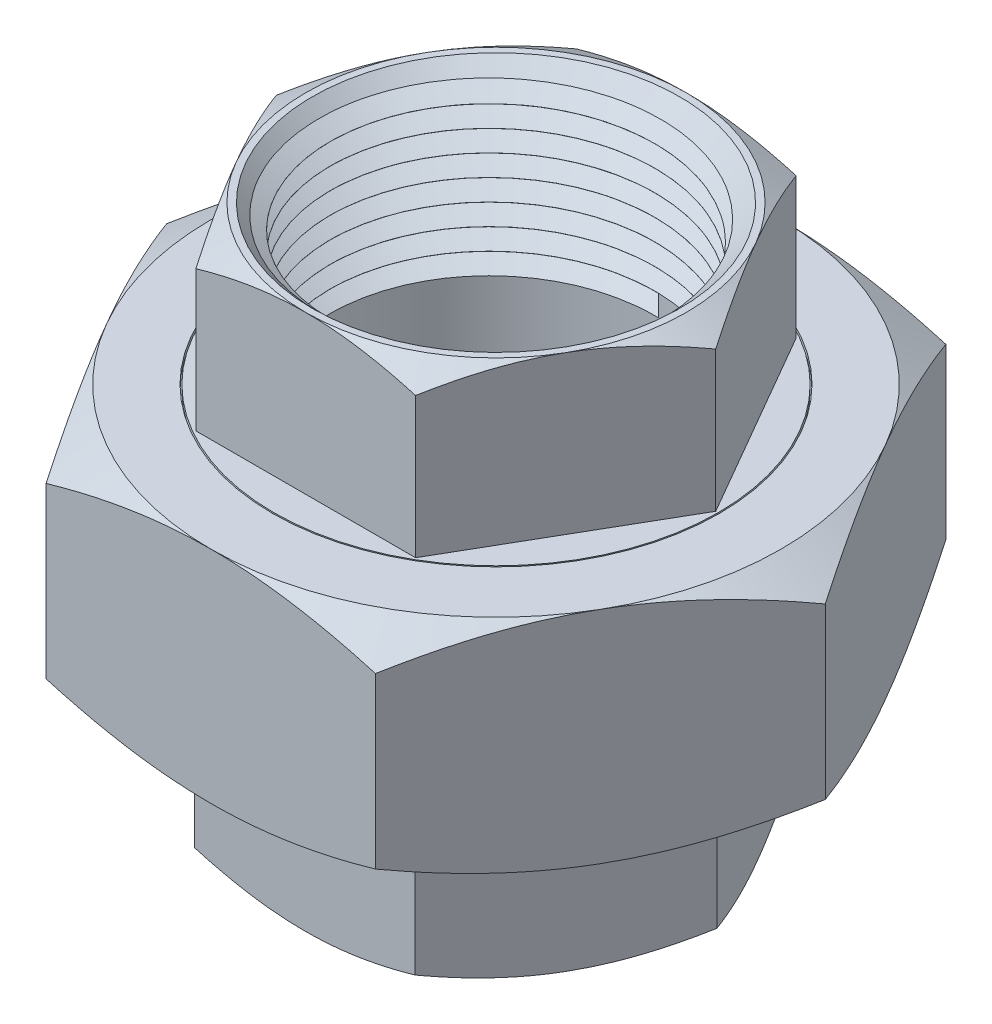
from build123d import *

# Parameters (mm, degrees)
BOSS_EXTRUDE1_DEPTH    = 20.7
SKETCH2_R              = 21
SKETCH2_R_2            = 20.875
CUT_EXTRUDE1_DEPTH     = 0.5
BOSS_EXTRUDE7_DEPTH    = 14.8
BOSS_EXTRUDE8_DEPTH    = 14.8
SKETCH7_OUTSIDE_W      = 100.43
SKETCH7_OUTSIDE_H      = 92.138
SKETCH7_OUTSIDE_R      = 26.8
CUT_EXTRUDE3_DEPTH     = 5
CUT_EXTRUDE3_TAPER     = 60
SKETCH8_OUTSIDE_W      = 100.43
SKETCH8_OUTSIDE_H      = 92.138
SKETCH8_OUTSIDE_R      = 26.8
CUT_EXTRUDE4_DEPTH     = 5
CUT_EXTRUDE4_TAPER     = 60
SKETCH9_OUTSIDE_W      = 100.43
SKETCH9_OUTSIDE_H      = 92.138
SKETCH9_OUTSIDE_R      = 17.970027129
CUT_EXTRUDE5_DEPTH     = 5
CUT_EXTRUDE5_TAPER     = 60
SKETCH10_OUTSIDE_W     = 100.43
SKETCH10_OUTSIDE_H     = 92.138
SKETCH10_OUTSIDE_R     = 17.883424588
CUT_EXTRUDE6_DEPTH     = 5
CUT_EXTRUDE6_TAPER     = 60
SKETCH14_R             = 15.25
CUT_EXTRUDE7_DEPTH     = 51.3
CHAMFER1_SIZE          = 2
CUT_SWEEP2_PITCH       = 2
CUT_SWEEP2_HEIGHT      = 15
CUT_SWEEP2_RADIUS      = 15.25
CUT_SWEEP2_START_ANGLE = 180
CUT_SWEEP3_PITCH       = 2
CUT_SWEEP3_HEIGHT      = 15
CUT_SWEEP3_RADIUS      = 15.25
CUT_SWEEP3_START_ANGLE = 180


with BuildPart() as part:
    # Sketch1 → Boss-Extrude1 (new body)
    with BuildSketch(Plane(origin=(0, 0, 0), x_dir=(1, 0, 0), z_dir=(0, 1, 0))):
        Polygon((30.945974429, 0), (15.472987214, 26.8), (-15.472987214, 26.8), (-30.945974429, 0), (-15.472987214, -26.8), (15.472987214, -26.8), align=None)
    extrude(amount=BOSS_EXTRUDE1_DEPTH)

    # Sketch2 → Cut-Extrude1 (cut)
    with BuildSketch(Plane(origin=(0, 20.7, 0), x_dir=(1, 0, 0), z_dir=(0, 1, 0))):
        Circle(SKETCH2_R)
        Circle(SKETCH2_R_2, mode=Mode.SUBTRACT)
    extrude(amount=-CUT_EXTRUDE1_DEPTH, mode=Mode.SUBTRACT)

    # Sketch5 → Boss-Extrude7 (add)
    with BuildSketch(Plane(origin=(0, 20.7, 0), x_dir=(1, 0, 0), z_dir=(0, 1, 0))):
        Polygon((20.65, 0), (10.325, 17.883424588), (-10.325, 17.883424588), (-20.65, 0), (-10.325, -17.883424588), (10.325, -17.883424588), align=None)
    extrude(amount=BOSS_EXTRUDE7_DEPTH)

    # Sketch6 → Boss-Extrude8 (add)
    with BuildSketch(Plane.XZ):
        Polygon((20.75, 0), (10.375, 17.970027129), (-10.375, 17.970027129), (-20.75, 0), (-10.375, -17.970027129), (10.375, -17.970027129), align=None)
    extrude(amount=BOSS_EXTRUDE8_DEPTH)

    # Sketch7 outside → Cut-Extrude3 (cut)
    with BuildSketch(Plane.XZ):
        Rectangle(SKETCH7_OUTSIDE_W, SKETCH7_OUTSIDE_H)
        Circle(SKETCH7_OUTSIDE_R, mode=Mode.SUBTRACT)
    extrude(amount=-CUT_EXTRUDE3_DEPTH, taper=CUT_EXTRUDE3_TAPER, mode=Mode.SUBTRACT)

    # Sketch8 outside → Cut-Extrude4 (cut)
    with BuildSketch(Plane(origin=(0, 20.7, 0), x_dir=(1, 0, 0), z_dir=(0, 1, 0))):
        Rectangle(SKETCH8_OUTSIDE_W, SKETCH8_OUTSIDE_H)
        Circle(SKETCH8_OUTSIDE_R, mode=Mode.SUBTRACT)
    extrude(amount=-CUT_EXTRUDE4_DEPTH, taper=CUT_EXTRUDE4_TAPER, mode=Mode.SUBTRACT)

    # Sketch9 outside → Cut-Extrude5 (cut)
    with BuildSketch(Plane.XZ.offset(14.8)):
        Rectangle(SKETCH9_OUTSIDE_W, SKETCH9_OUTSIDE_H)
        Circle(SKETCH9_OUTSIDE_R, mode=Mode.SUBTRACT)
    extrude(amount=-CUT_EXTRUDE5_DEPTH, taper=CUT_EXTRUDE5_TAPER, mode=Mode.SUBTRACT)

    # Sketch10 outside → Cut-Extrude6 (cut)
    with BuildSketch(Plane(origin=(0, 35.5, 0), x_dir=(1, 0, 0), z_dir=(0, 1, 0))):
        Rectangle(SKETCH10_OUTSIDE_W, SKETCH10_OUTSIDE_H)
        Circle(SKETCH10_OUTSIDE_R, mode=Mode.SUBTRACT)
    extrude(amount=-CUT_EXTRUDE6_DEPTH, taper=CUT_EXTRUDE6_TAPER, mode=Mode.SUBTRACT)

    # Cut-Sweep1: sweep along a path in Sketch13
    with BuildLine(Plane.XZ) as cut_sweep1_path:
        CenterArc((0, 0), 23.25, 0, 360)
    # Sketch12 → Cut-Sweep1 (sweep, cut)
    with BuildSketch(Plane(origin=(0, 0, 0), x_dir=(0, 0, -1), z_dir=(1, 0, 0))):
        Polygon((23.25, 1.335741012), (22.434038991, 0), (24.10439639, 0), align=None)
    sweep(path=cut_sweep1_path.line, mode=Mode.SUBTRACT)

    # Sketch14 → Cut-Extrude7 (cut, through all)
    with BuildSketch(Plane.XZ.offset(14.8)):
        Circle(SKETCH14_R)
    extrude(amount=-CUT_EXTRUDE7_DEPTH, mode=Mode.SUBTRACT)

    # Chamfer1
    chamfer1_edges = [part.edges().sort_by_distance(p)[0] for p in [
        (-15.25, 35.5, 0),
        (-15.25, -14.8, 0),
    ]]
    chamfer(chamfer1_edges, length=CHAMFER1_SIZE)

    # Cut-Sweep2: sweep along a helix
    with BuildLine() as cut_sweep2_path:
        add(Helix(CUT_SWEEP2_PITCH, CUT_SWEEP2_HEIGHT, CUT_SWEEP2_RADIUS, center=(0, -14.8, 0), direction=(0, 1, 0), mode=Mode.PRIVATE).rotate(Axis((0, -14.8, 0), (0, 1, 0)), CUT_SWEEP2_START_ANGLE))
    # Sketch16 → Cut-Sweep2 (sweep, cut)
    with BuildSketch(Plane(origin=(0, 0, 0), x_dir=(0, 0, -1), z_dir=(1, 0, 0))):
        Polygon((15.205623927, -14.8), (15.205623927, -12.81), (16.94055188, -13.805), align=None)
    sweep(path=cut_sweep2_path.line, is_frenet=True, mode=Mode.SUBTRACT)

    # Cut-Sweep3: sweep along a helix
    with BuildLine() as cut_sweep3_path:
        add(Helix(CUT_SWEEP3_PITCH, CUT_SWEEP3_HEIGHT, CUT_SWEEP3_RADIUS, center=(0, 35.5, 0), direction=(0, -1, 0), mode=Mode.PRIVATE).rotate(Axis((0, 35.5, 0), (0, -1, 0)), CUT_SWEEP3_START_ANGLE))
    # Sketch18 → Cut-Sweep3 (sweep, cut)
    with BuildSketch(Plane(origin=(0, 0, 0), x_dir=(0, 0, -1), z_dir=(1, 0, 0))):
        Polygon((-15.249985698, 35.499568847), (-15.249985698, 33.509568847), (-16.984913651, 34.504568847), align=None)
    sweep(path=cut_sweep3_path.line, is_frenet=True, mode=Mode.SUBTRACT)


solid = part.part
